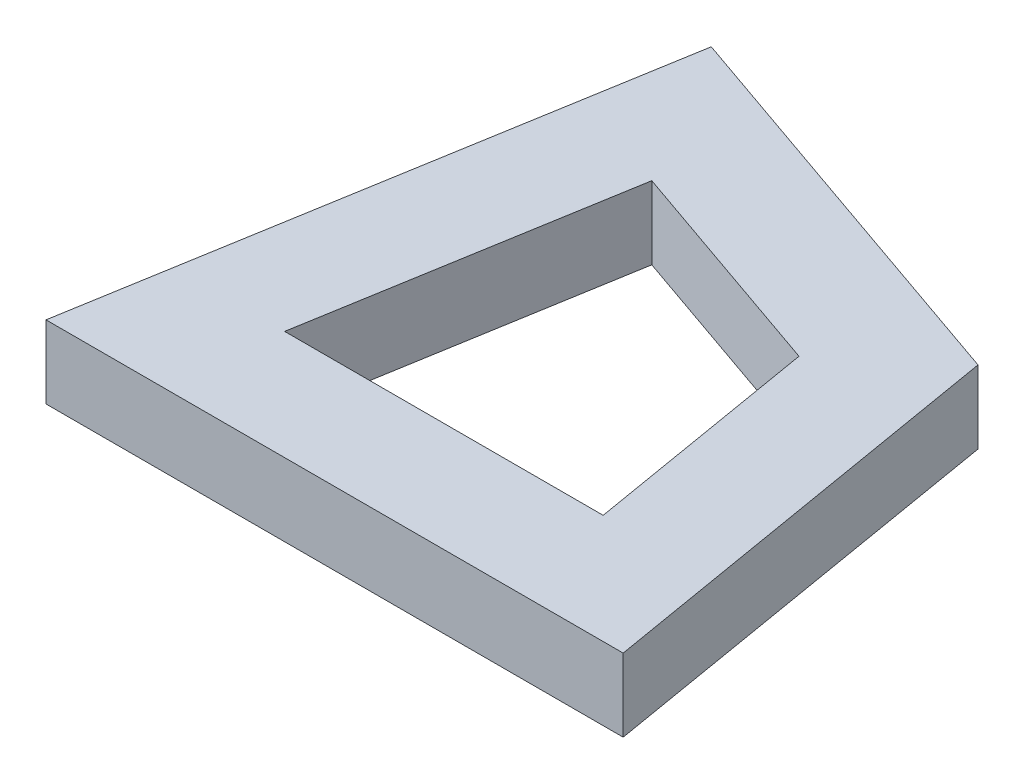
from build123d import *

# Parameters (mm, degrees)
BOSS_EXTRUDE1_DEPTH = 2


with BuildPart() as part:
    # Sketch1 → Boss-Extrude1 (new body)
    with BuildSketch(Plane(origin=(0, 0, 0), x_dir=(1, 0, 0), z_dir=(0, 1, 0))):
        Polygon((0, 0), (15.84078026, 0), (13.860874637, 11.718342674), (2.63902101, 15.619407394), align=None)
        Polygon((5.005894234, 11.620506435), (3.549392266, 3), (12.291387994, 3), (11.198615402, 9.467724294), align=None, mode=Mode.SUBTRACT)
    extrude(amount=BOSS_EXTRUDE1_DEPTH)


solid = part.part
